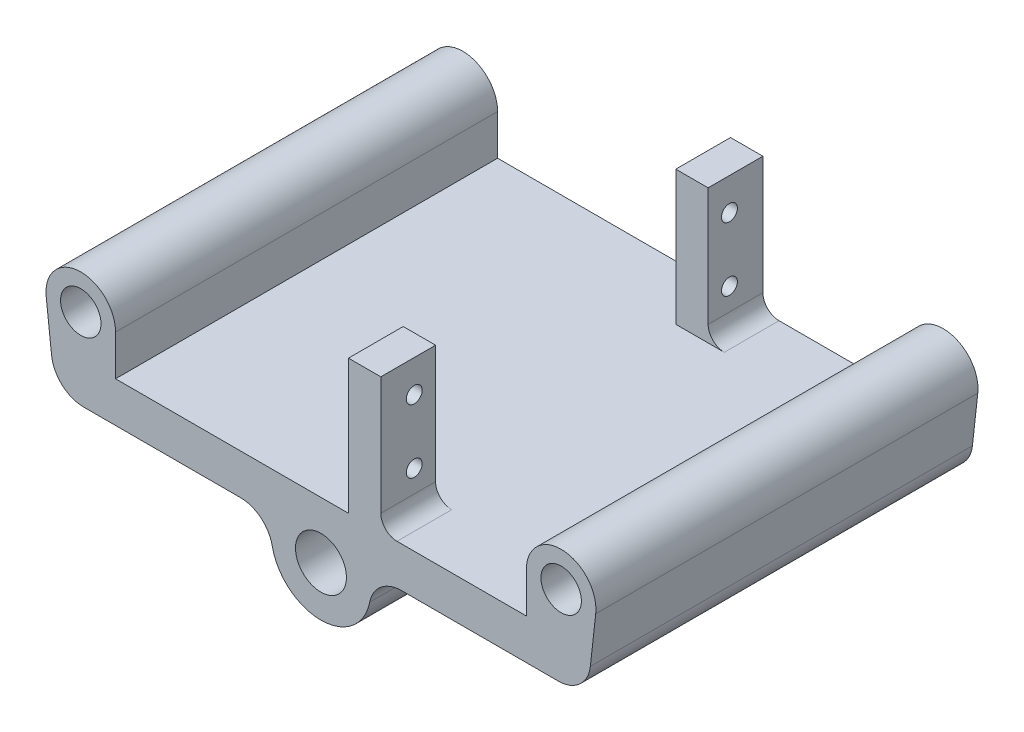
from build123d import *

# Parameters (mm, degrees)
SKETCH1_R           = 3.175
BOSS_EXTRUDE1_DEPTH = 60
SKETCH2_R           = 4
CUT_EXTRUDE1_DEPTH  = 61
BOSS_EXTRUDE2_DEPTH = 60
SKETCH5_W           = 5.08
SKETCH5_H           = 8.6
BOSS_EXTRUDE3_DEPTH = 21.1
CUT_EXTRUDE2_REACH  = 54.578
SKETCH6_R           = 1.25
FILLET1_R           = 2.54
FILLET3_R           = 5.08
FILLET4_R           = 5.08


with BuildPart() as part:
    # Sketch1 → Boss-Extrude1 (new body)
    with BuildSketch(Plane.XY):
        with BuildLine():
            Line((0, 0), (41.801331845, 0))
            Line((41.801331845, 0), (43.146541753, 12.096417759))
            ThreePointArc((43.146541753, 12.096417759), (38.021254436, 18.152629022), (32.258, 12.7))
            Line((32.258, 12.7), (32.258, 6.35))
            Line((32.258, 6.35), (0, 6.35))
            Line((0, 6.35), (0, 0))
        make_face()
        with Locations((37.719, 12.7)):
            Circle(SKETCH1_R, mode=Mode.SUBTRACT)
    boss_extrude1 = extrude(amount=BOSS_EXTRUDE1_DEPTH)

    # Sketch2 → Cut-Extrude1 (cut, through all)
    with BuildSketch(Plane(origin=(0, 0, 0), x_dir=(-1, 0, 0), z_dir=(0, 0, -1))):
        with Locations((0, -2.54)):
            Circle(SKETCH2_R)
    cut_extrude1 = extrude(amount=-CUT_EXTRUDE1_DEPTH, mode=Mode.SUBTRACT)

    # Sketch3 → Boss-Extrude2 (add)
    with BuildSketch(Plane(origin=(0, 0, 0), x_dir=(-1, 0, 0), z_dir=(0, 0, -1))):
        with BuildLine():
            Line((-7.385424835, 0), (-3.090048543, 0))
            ThreePointArc((-3.090048543, 0), (-3.616628264, -4.248800749), (0, -6.54))
            Line((0, -6.54), (0, -10.35))
            ThreePointArc((0, -10.35), (-6.357416928, -7.076446847), (-7.385424835, 0))
        make_face()
    boss_extrude2 = extrude(amount=-BOSS_EXTRUDE2_DEPTH)

    # Mirror1: Boss-Extrude1, Cut-Extrude1, Boss-Extrude2 across plane
    add(boss_extrude1.mirror(Plane(origin=(0, 0, 0), x_dir=(0, 0, 1), z_dir=(1, 0, 0))))
    add(cut_extrude1.mirror(Plane(origin=(0, 0, 0), x_dir=(0, 0, 1), z_dir=(1, 0, 0))), mode=Mode.SUBTRACT)
    add(boss_extrude2.mirror(Plane(origin=(0, 0, 0), x_dir=(0, 0, 1), z_dir=(1, 0, 0))))

    # Sketch5 → Boss-Extrude3 (add)
    with BuildSketch(Plane(origin=(0, 6.35, 0), x_dir=(1, 0, 0), z_dir=(0, 1, 0))):
        with Locations((6.858, -4.3)):
            Rectangle(SKETCH5_W, SKETCH5_H)
        with Locations((6.858, -55.7)):
            Rectangle(SKETCH5_W, SKETCH5_H)
    extrude(amount=BOSS_EXTRUDE3_DEPTH)

    # Sketch6 → Cut-Extrude2 (cut, up to next)
    with BuildSketch(Plane(origin=(9.398, 0, 0), x_dir=(0, 0, -1), z_dir=(1, 0, 0)), mode=Mode.PRIVATE) as cut_extrude2_sk1:
        with Locations((-54.75, 22.4)):
            Circle(SKETCH6_R)
    cut_extrude2_tool1 = extrude(cut_extrude2_sk1.sketch, amount=-CUT_EXTRUDE2_REACH, mode=Mode.PRIVATE) & part.part
    add(cut_extrude2_tool1.solids().sort_by_distance((9.398, 22.4, 54.75))[0], mode=Mode.SUBTRACT)
    # Sketch6 → Cut-Extrude2 (cut, up to next)
    with BuildSketch(Plane(origin=(9.398, 0, 0), x_dir=(0, 0, -1), z_dir=(1, 0, 0)), mode=Mode.PRIVATE) as cut_extrude2_sk2:
        with Locations((-5.25, 22.4)):
            Circle(SKETCH6_R)
    cut_extrude2_tool2 = extrude(cut_extrude2_sk2.sketch, amount=-CUT_EXTRUDE2_REACH, mode=Mode.PRIVATE) & part.part
    add(cut_extrude2_tool2.solids().sort_by_distance((9.398, 22.4, 5.25))[0], mode=Mode.SUBTRACT)
    # Sketch6 → Cut-Extrude2 (cut, up to next)
    with BuildSketch(Plane(origin=(9.398, 0, 0), x_dir=(0, 0, -1), z_dir=(1, 0, 0)), mode=Mode.PRIVATE) as cut_extrude2_sk3:
        with Locations((-5.25, 12.4)):
            Circle(SKETCH6_R)
    cut_extrude2_tool3 = extrude(cut_extrude2_sk3.sketch, amount=-CUT_EXTRUDE2_REACH, mode=Mode.PRIVATE) & part.part
    add(cut_extrude2_tool3.solids().sort_by_distance((9.398, 12.4, 5.25))[0], mode=Mode.SUBTRACT)
    # Sketch6 → Cut-Extrude2 (cut, up to next)
    with BuildSketch(Plane(origin=(9.398, 0, 0), x_dir=(0, 0, -1), z_dir=(1, 0, 0)), mode=Mode.PRIVATE) as cut_extrude2_sk4:
        with Locations((-54.75, 12.4)):
            Circle(SKETCH6_R)
    cut_extrude2_tool4 = extrude(cut_extrude2_sk4.sketch, amount=-CUT_EXTRUDE2_REACH, mode=Mode.PRIVATE) & part.part
    add(cut_extrude2_tool4.solids().sort_by_distance((9.398, 12.4, 54.75))[0], mode=Mode.SUBTRACT)

    # Fillet1
    fillet1_edges = [part.edges().sort_by_distance(p)[0] for p in [
        (9.398, 6.35, 55.7),
        (9.398, 6.35, 4.3),
    ]]
    fillet(fillet1_edges, radius=FILLET1_R)

    # Fillet3
    fillet3_edges = [part.edges().sort_by_distance(p)[0] for p in [
        (7.385424835, 0, 30),
        (-7.385424835, 0, 30),
    ]]
    fillet(fillet3_edges, radius=FILLET3_R)

    # Fillet4
    fillet4_edges = [part.edges().sort_by_distance(p)[0] for p in [
        (41.801331845, 0, 30),
        (-41.801331845, 0, 30),
    ]]
    fillet(fillet4_edges, radius=FILLET4_R)


solid = part.part
